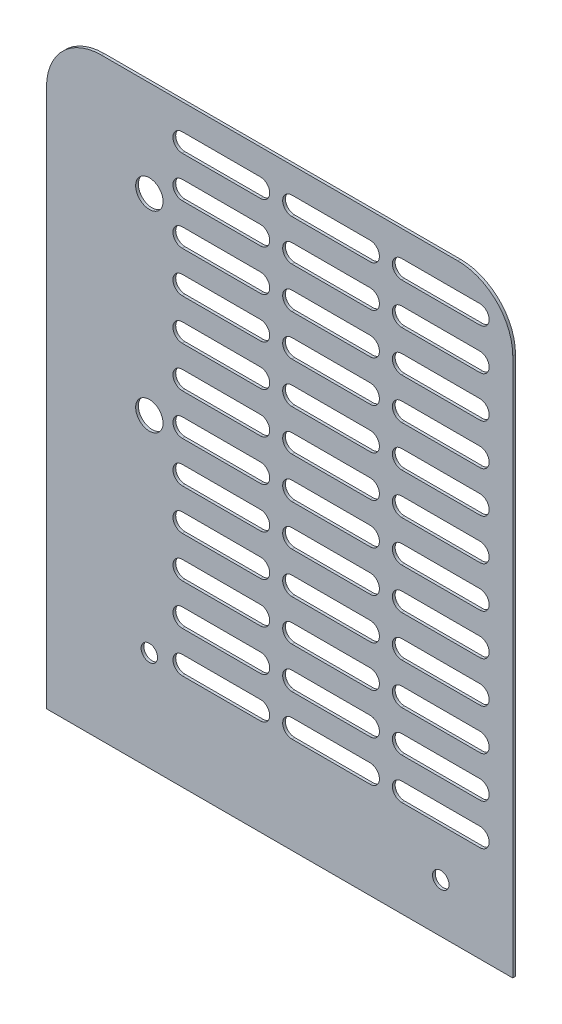
from build123d import *

# Parameters (mm, degrees)
ESBO_O1_R                = 5
RESSALTO_EXTRUS_O1_DEPTH = 1
ESBO_O2_R                = 3
CORTE_EXTRUS_O2_DEPTH    = 1


with BuildPart() as part:
    # Esboço1 → Ressalto-extrusão1 (new body)
    with BuildSketch(Plane.XY):
        with BuildLine():
            Line((55, -10), (185, -10))
            ThreePointArc((185, -10), (199.142135624, -15.857864376), (205, -30))
            Line((205, -30), (205, -226.427576987))
            Line((205, -226.427576987), (35, -226.427576987))
            Line((35, -226.427576987), (35, -30))
            ThreePointArc((35, -30), (40.857864376, -15.857864376), (55, -10))
        make_face()
        with Locations((72.5, -45)):
            Circle(ESBO_O1_R, mode=Mode.SUBTRACT)
        with Locations((72.5, -115)):
            Circle(ESBO_O1_R, mode=Mode.SUBTRACT)
        with BuildLine():
            Line((84.5, -19.479653367), (113, -19.479653367))
            ThreePointArc((113, -19.479653367), (116.385842108, -22.865495475), (113, -26.251337583))
            Line((113, -26.251337583), (84.5, -26.251337583))
            ThreePointArc((84.5, -26.251337583), (81.114157892, -22.865495475), (84.5, -19.479653367))
        make_face(mode=Mode.SUBTRACT)
        with BuildLine():
            Line((124.5, -19.479653367), (153, -19.479653367))
            ThreePointArc((153, -19.479653367), (156.385842108, -22.865495475), (153, -26.251337583))
            Line((153, -26.251337583), (124.5, -26.251337583))
            ThreePointArc((124.5, -26.251337583), (121.114157892, -22.865495475), (124.5, -19.479653367))
        make_face(mode=Mode.SUBTRACT)
        with BuildLine():
            Line((164.5, -19.479653367), (193, -19.479653367))
            ThreePointArc((193, -19.479653367), (196.385842108, -22.865495475), (193, -26.251337583))
            Line((193, -26.251337583), (164.5, -26.251337583))
            ThreePointArc((164.5, -26.251337583), (161.114157892, -22.865495475), (164.5, -19.479653367))
        make_face(mode=Mode.SUBTRACT)
        with BuildLine():
            Line((124.5, -34.479653367), (153, -34.479653367))
            ThreePointArc((153, -34.479653367), (156.385842108, -37.865495475), (153, -41.251337583))
            Line((153, -41.251337583), (124.5, -41.251337583))
            ThreePointArc((124.5, -41.251337583), (121.114157892, -37.865495475), (124.5, -34.479653367))
        make_face(mode=Mode.SUBTRACT)
        with BuildLine():
            Line((164.5, -34.479653367), (193, -34.479653367))
            ThreePointArc((193, -34.479653367), (196.385842108, -37.865495475), (193, -41.251337583))
            Line((193, -41.251337583), (164.5, -41.251337583))
            ThreePointArc((164.5, -41.251337583), (161.114157892, -37.865495475), (164.5, -34.479653367))
        make_face(mode=Mode.SUBTRACT)
        with BuildLine():
            Line((124.5, -49.479653367), (153, -49.479653367))
            ThreePointArc((153, -49.479653367), (156.385842108, -52.865495475), (153, -56.251337583))
            Line((153, -56.251337583), (124.5, -56.251337583))
            ThreePointArc((124.5, -56.251337583), (121.114157892, -52.865495475), (124.5, -49.479653367))
        make_face(mode=Mode.SUBTRACT)
        with BuildLine():
            Line((164.5, -49.479653367), (193, -49.479653367))
            ThreePointArc((193, -49.479653367), (196.385842108, -52.865495475), (193, -56.251337583))
            Line((193, -56.251337583), (164.5, -56.251337583))
            ThreePointArc((164.5, -56.251337583), (161.114157892, -52.865495475), (164.5, -49.479653367))
        make_face(mode=Mode.SUBTRACT)
        with BuildLine():
            Line((124.5, -64.479653367), (153, -64.479653367))
            ThreePointArc((153, -64.479653367), (156.385842108, -67.865495475), (153, -71.251337583))
            Line((153, -71.251337583), (124.5, -71.251337583))
            ThreePointArc((124.5, -71.251337583), (121.114157892, -67.865495475), (124.5, -64.479653367))
        make_face(mode=Mode.SUBTRACT)
        with BuildLine():
            Line((164.5, -64.479653367), (193, -64.479653367))
            ThreePointArc((193, -64.479653367), (196.385842108, -67.865495475), (193, -71.251337583))
            Line((193, -71.251337583), (164.5, -71.251337583))
            ThreePointArc((164.5, -71.251337583), (161.114157892, -67.865495475), (164.5, -64.479653367))
        make_face(mode=Mode.SUBTRACT)
        with BuildLine():
            Line((124.5, -79.479653367), (153, -79.479653367))
            ThreePointArc((153, -79.479653367), (156.385842108, -82.865495475), (153, -86.251337583))
            Line((153, -86.251337583), (124.5, -86.251337583))
            ThreePointArc((124.5, -86.251337583), (121.114157892, -82.865495475), (124.5, -79.479653367))
        make_face(mode=Mode.SUBTRACT)
        with BuildLine():
            Line((164.5, -79.479653367), (193, -79.479653367))
            ThreePointArc((193, -79.479653367), (196.385842108, -82.865495475), (193, -86.251337583))
            Line((193, -86.251337583), (164.5, -86.251337583))
            ThreePointArc((164.5, -86.251337583), (161.114157892, -82.865495475), (164.5, -79.479653367))
        make_face(mode=Mode.SUBTRACT)
        with BuildLine():
            Line((124.5, -94.479653367), (153, -94.479653367))
            ThreePointArc((153, -94.479653367), (156.385842108, -97.865495475), (153, -101.251337583))
            Line((153, -101.251337583), (124.5, -101.251337583))
            ThreePointArc((124.5, -101.251337583), (121.114157892, -97.865495475), (124.5, -94.479653367))
        make_face(mode=Mode.SUBTRACT)
        with BuildLine():
            Line((164.5, -94.479653367), (193, -94.479653367))
            ThreePointArc((193, -94.479653367), (196.385842108, -97.865495475), (193, -101.251337583))
            Line((193, -101.251337583), (164.5, -101.251337583))
            ThreePointArc((164.5, -101.251337583), (161.114157892, -97.865495475), (164.5, -94.479653367))
        make_face(mode=Mode.SUBTRACT)
        with BuildLine():
            Line((124.5, -109.479653367), (153, -109.479653367))
            ThreePointArc((153, -109.479653367), (156.385842108, -112.865495475), (153, -116.251337583))
            Line((153, -116.251337583), (124.5, -116.251337583))
            ThreePointArc((124.5, -116.251337583), (121.114157892, -112.865495475), (124.5, -109.479653367))
        make_face(mode=Mode.SUBTRACT)
        with BuildLine():
            Line((164.5, -109.479653367), (193, -109.479653367))
            ThreePointArc((193, -109.479653367), (196.385842108, -112.865495475), (193, -116.251337583))
            Line((193, -116.251337583), (164.5, -116.251337583))
            ThreePointArc((164.5, -116.251337583), (161.114157892, -112.865495475), (164.5, -109.479653367))
        make_face(mode=Mode.SUBTRACT)
        with BuildLine():
            Line((124.5, -124.479653367), (153, -124.479653367))
            ThreePointArc((153, -124.479653367), (156.385842108, -127.865495475), (153, -131.251337583))
            Line((153, -131.251337583), (124.5, -131.251337583))
            ThreePointArc((124.5, -131.251337583), (121.114157892, -127.865495475), (124.5, -124.479653367))
        make_face(mode=Mode.SUBTRACT)
        with BuildLine():
            Line((164.5, -124.479653367), (193, -124.479653367))
            ThreePointArc((193, -124.479653367), (196.385842108, -127.865495475), (193, -131.251337583))
            Line((193, -131.251337583), (164.5, -131.251337583))
            ThreePointArc((164.5, -131.251337583), (161.114157892, -127.865495475), (164.5, -124.479653367))
        make_face(mode=Mode.SUBTRACT)
        with BuildLine():
            Line((124.5, -139.479653367), (153, -139.479653367))
            ThreePointArc((153, -139.479653367), (156.385842108, -142.865495475), (153, -146.251337583))
            Line((153, -146.251337583), (124.5, -146.251337583))
            ThreePointArc((124.5, -146.251337583), (121.114157892, -142.865495475), (124.5, -139.479653367))
        make_face(mode=Mode.SUBTRACT)
        with BuildLine():
            Line((164.5, -139.479653367), (193, -139.479653367))
            ThreePointArc((193, -139.479653367), (196.385842108, -142.865495475), (193, -146.251337583))
            Line((193, -146.251337583), (164.5, -146.251337583))
            ThreePointArc((164.5, -146.251337583), (161.114157892, -142.865495475), (164.5, -139.479653367))
        make_face(mode=Mode.SUBTRACT)
        with BuildLine():
            Line((124.5, -154.479653367), (153, -154.479653367))
            ThreePointArc((153, -154.479653367), (156.385842108, -157.865495475), (153, -161.251337583))
            Line((153, -161.251337583), (124.5, -161.251337583))
            ThreePointArc((124.5, -161.251337583), (121.114157892, -157.865495475), (124.5, -154.479653367))
        make_face(mode=Mode.SUBTRACT)
        with BuildLine():
            Line((164.5, -154.479653367), (193, -154.479653367))
            ThreePointArc((193, -154.479653367), (196.385842108, -157.865495475), (193, -161.251337583))
            Line((193, -161.251337583), (164.5, -161.251337583))
            ThreePointArc((164.5, -161.251337583), (161.114157892, -157.865495475), (164.5, -154.479653367))
        make_face(mode=Mode.SUBTRACT)
        with BuildLine():
            Line((124.5, -169.479653367), (153, -169.479653367))
            ThreePointArc((153, -169.479653367), (156.385842108, -172.865495475), (153, -176.251337583))
            Line((153, -176.251337583), (124.5, -176.251337583))
            ThreePointArc((124.5, -176.251337583), (121.114157892, -172.865495475), (124.5, -169.479653367))
        make_face(mode=Mode.SUBTRACT)
        with BuildLine():
            Line((164.5, -169.479653367), (193, -169.479653367))
            ThreePointArc((193, -169.479653367), (196.385842108, -172.865495475), (193, -176.251337583))
            Line((193, -176.251337583), (164.5, -176.251337583))
            ThreePointArc((164.5, -176.251337583), (161.114157892, -172.865495475), (164.5, -169.479653367))
        make_face(mode=Mode.SUBTRACT)
        with BuildLine():
            Line((124.5, -184.479653367), (153, -184.479653367))
            ThreePointArc((153, -184.479653367), (156.385842108, -187.865495475), (153, -191.251337583))
            Line((153, -191.251337583), (124.5, -191.251337583))
            ThreePointArc((124.5, -191.251337583), (121.114157892, -187.865495475), (124.5, -184.479653367))
        make_face(mode=Mode.SUBTRACT)
        with BuildLine():
            Line((164.5, -184.479653367), (193, -184.479653367))
            ThreePointArc((193, -184.479653367), (196.385842108, -187.865495475), (193, -191.251337583))
            Line((193, -191.251337583), (164.5, -191.251337583))
            ThreePointArc((164.5, -191.251337583), (161.114157892, -187.865495475), (164.5, -184.479653367))
        make_face(mode=Mode.SUBTRACT)
        with BuildLine():
            Line((84.5, -34.479653367), (113, -34.479653367))
            ThreePointArc((113, -34.479653367), (116.385842108, -37.865495475), (113, -41.251337583))
            Line((113, -41.251337583), (84.5, -41.251337583))
            ThreePointArc((84.5, -41.251337583), (81.114157892, -37.865495475), (84.5, -34.479653367))
        make_face(mode=Mode.SUBTRACT)
        with BuildLine():
            Line((84.5, -49.479653367), (113, -49.479653367))
            ThreePointArc((113, -49.479653367), (116.385842108, -52.865495475), (113, -56.251337583))
            Line((113, -56.251337583), (84.5, -56.251337583))
            ThreePointArc((84.5, -56.251337583), (81.114157892, -52.865495475), (84.5, -49.479653367))
        make_face(mode=Mode.SUBTRACT)
        with BuildLine():
            Line((84.5, -64.479653367), (113, -64.479653367))
            ThreePointArc((113, -64.479653367), (116.385842108, -67.865495475), (113, -71.251337583))
            Line((113, -71.251337583), (84.5, -71.251337583))
            ThreePointArc((84.5, -71.251337583), (81.114157892, -67.865495475), (84.5, -64.479653367))
        make_face(mode=Mode.SUBTRACT)
        with BuildLine():
            Line((84.5, -79.479653367), (113, -79.479653367))
            ThreePointArc((113, -79.479653367), (116.385842108, -82.865495475), (113, -86.251337583))
            Line((113, -86.251337583), (84.5, -86.251337583))
            ThreePointArc((84.5, -86.251337583), (81.114157892, -82.865495475), (84.5, -79.479653367))
        make_face(mode=Mode.SUBTRACT)
        with BuildLine():
            Line((84.5, -94.479653367), (113, -94.479653367))
            ThreePointArc((113, -94.479653367), (116.385842108, -97.865495475), (113, -101.251337583))
            Line((113, -101.251337583), (84.5, -101.251337583))
            ThreePointArc((84.5, -101.251337583), (81.114157892, -97.865495475), (84.5, -94.479653367))
        make_face(mode=Mode.SUBTRACT)
        with BuildLine():
            Line((84.5, -109.479653367), (113, -109.479653367))
            ThreePointArc((113, -109.479653367), (116.385842108, -112.865495475), (113, -116.251337583))
            Line((113, -116.251337583), (84.5, -116.251337583))
            ThreePointArc((84.5, -116.251337583), (81.114157892, -112.865495475), (84.5, -109.479653367))
        make_face(mode=Mode.SUBTRACT)
        with BuildLine():
            Line((84.5, -124.479653367), (113, -124.479653367))
            ThreePointArc((113, -124.479653367), (116.385842108, -127.865495475), (113, -131.251337583))
            Line((113, -131.251337583), (84.5, -131.251337583))
            ThreePointArc((84.5, -131.251337583), (81.114157892, -127.865495475), (84.5, -124.479653367))
        make_face(mode=Mode.SUBTRACT)
        with BuildLine():
            Line((84.5, -139.479653367), (113, -139.479653367))
            ThreePointArc((113, -139.479653367), (116.385842108, -142.865495475), (113, -146.251337583))
            Line((113, -146.251337583), (84.5, -146.251337583))
            ThreePointArc((84.5, -146.251337583), (81.114157892, -142.865495475), (84.5, -139.479653367))
        make_face(mode=Mode.SUBTRACT)
        with BuildLine():
            Line((84.5, -154.479653367), (113, -154.479653367))
            ThreePointArc((113, -154.479653367), (116.385842108, -157.865495475), (113, -161.251337583))
            Line((113, -161.251337583), (84.5, -161.251337583))
            ThreePointArc((84.5, -161.251337583), (81.114157892, -157.865495475), (84.5, -154.479653367))
        make_face(mode=Mode.SUBTRACT)
        with BuildLine():
            Line((84.5, -169.479653367), (113, -169.479653367))
            ThreePointArc((113, -169.479653367), (116.385842108, -172.865495475), (113, -176.251337583))
            Line((113, -176.251337583), (84.5, -176.251337583))
            ThreePointArc((84.5, -176.251337583), (81.114157892, -172.865495475), (84.5, -169.479653367))
        make_face(mode=Mode.SUBTRACT)
        with BuildLine():
            Line((84.5, -184.479653367), (113, -184.479653367))
            ThreePointArc((113, -184.479653367), (116.385842108, -187.865495475), (113, -191.251337583))
            Line((113, -191.251337583), (84.5, -191.251337583))
            ThreePointArc((84.5, -191.251337583), (81.114157892, -187.865495475), (84.5, -184.479653367))
        make_face(mode=Mode.SUBTRACT)
    extrude(amount=RESSALTO_EXTRUS_O1_DEPTH)

    # Esboço2 → Corte-extrusão2 (cut)
    with BuildSketch(Plane.XY.offset(1)):
        with Locations((72.5, -190)):
            Circle(ESBO_O2_R)
        with Locations((178.75, -208.570727001)):
            Circle(ESBO_O2_R)
    extrude(amount=-CORTE_EXTRUS_O2_DEPTH, mode=Mode.SUBTRACT)


solid = part.part
